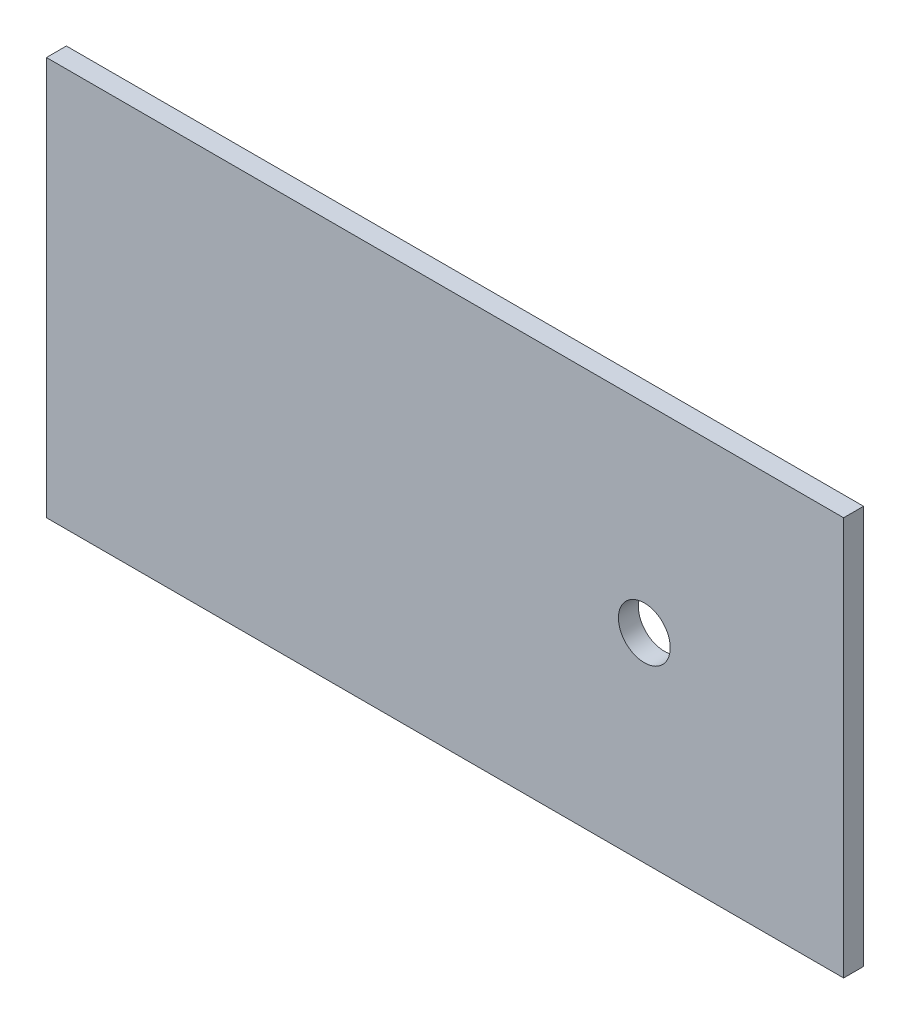
from build123d import *

# Parameters (mm, degrees)
SKETCH1_W           = 200
SKETCH1_H           = 100
BOSS_EXTRUDE1_DEPTH = 5
SKETCH2_R           = 6.5
CUT_EXTRUDE1_DEPTH  = 5


with BuildPart() as part:
    # Sketch1 → Boss-Extrude1 (new body)
    with BuildSketch(Plane.XY):
        Rectangle(SKETCH1_W, SKETCH1_H)
    extrude(amount=BOSS_EXTRUDE1_DEPTH)

    # Sketch2 → Cut-Extrude1 (cut)
    with BuildSketch(Plane.XY.offset(5)):
        with Locations((50, 0)):
            Circle(SKETCH2_R)
    extrude(amount=-CUT_EXTRUDE1_DEPTH, mode=Mode.SUBTRACT)


solid = part.part
